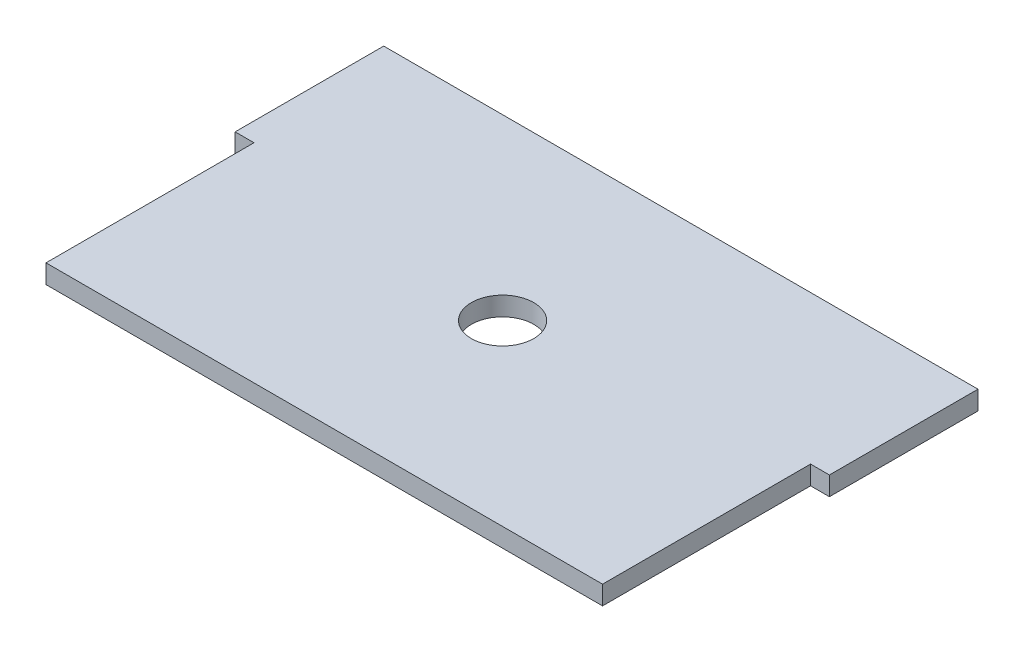
from build123d import *

# Parameters (mm, degrees)
SKETCH1_W                    = 100
SKETCH1_H                    = 60
BOSS_EXTRUDE1_DEPTH          = 3.175
CUT_EXTRUDE1_DEPTH           = 3.175
TAP_DRILL_FOR_M12X1_5_TAP1_D = 10.5


with BuildPart() as part:
    # Sketch1 → Boss-Extrude1 (new body)
    with BuildSketch(Plane(origin=(0, 0, 0), x_dir=(1, 0, 0), z_dir=(0, 1, 0))):
        with Locations((50, -30)):
            Rectangle(SKETCH1_W, SKETCH1_H)
    extrude(amount=BOSS_EXTRUDE1_DEPTH)

    # Sketch2 → Cut-Extrude1 (cut)
    with BuildSketch(Plane(origin=(0, 3.175, 0), x_dir=(1, 0, 0), z_dir=(0, 1, 0))):
        Polygon((3.175, -25), (3.175, -35), (3.175, -60), (0, -60), (0, -45), (0, -25), align=None)
        Polygon((100, -25), (96.825, -25), (96.825, -35), (96.825, -60), (100, -60), (100, -45), align=None)
    extrude(amount=-CUT_EXTRUDE1_DEPTH, mode=Mode.SUBTRACT)

    # Tap Drill for M12x1.5 Tap1 (through all)
    with Locations(Plane(origin=(0, 3.175, 0), x_dir=(1, 0, 0), z_dir=(0, 1, 0))):
        with Locations((50, -30)):
            Hole(TAP_DRILL_FOR_M12X1_5_TAP1_D / 2)


solid = part.part
